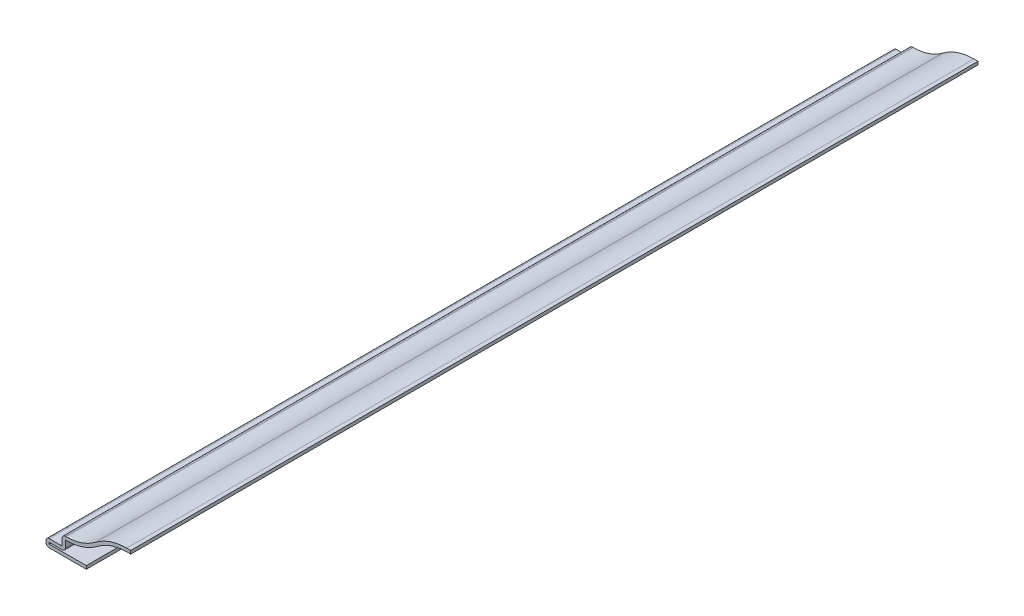
from build123d import *

# Parameters (mm, degrees)
EXTRUDE_THIN1_DEPTH = 333.375
FILLET1_R           = 1.27


with BuildPart() as part:
    # Sketch1 → Extrude-Thin1 (new body)
    with BuildSketch(Plane.XY):
        with BuildLine():
            Line((0, 15.160625), (-1.5875, 15.160625))
            ThreePointArc((-1.5875, 15.160625), (-8.061044421, 14.097490008), (-13.854545455, 11.019766961))
            ThreePointArc((-13.854545455, 11.019766961), (-19.30725231, 8.123086446), (-25.4, 7.122488807))
            Line((-25.4, 7.122488807), (-26.9875, 7.122488807))
            Line((-26.9875, 7.122488807), (-26.9875, 3.175))
            Line((-26.9875, 3.175), (-33.3375, 3.175))
            Line((-33.3375, 3.175), (-33.3375, 0))
            Line((-33.3375, 0), (-17.4625, 0))
            Line((-17.4625, 0), (-17.4625, 1.27))
            Line((-17.4625, 1.27), (-32.0675, 1.27))
            Line((-32.0675, 1.27), (-32.0675, 1.905))
            Line((-32.0675, 1.905), (-25.7175, 1.905))
            Line((-25.7175, 1.905), (-25.7175, 5.852488807))
            Line((-25.7175, 5.852488807), (-25.4, 5.852488807))
            ThreePointArc((-25.4, 5.852488807), (-18.90106913, 6.919792956), (-13.084848485, 10.009585505))
            ThreePointArc((-13.084848485, 10.009585505), (-7.654861242, 12.894196518), (-1.5875, 13.890625))
            Line((-1.5875, 13.890625), (0, 13.890625))
            Line((0, 13.890625), (0, 15.160625))
        make_face()
    extrude(amount=-EXTRUDE_THIN1_DEPTH)

    # Fillet1
    fillet1_edges = [part.edges().sort_by_distance(p)[0] for p in [
        (-33.3375, 0, -166.6875),
        (-33.3375, 3.175, -166.6875),
        (-26.9875, 7.122488807, -166.6875),
        (-25.7175, 1.905, -166.6875),
    ]]
    fillet(fillet1_edges, radius=FILLET1_R)


solid = part.part
